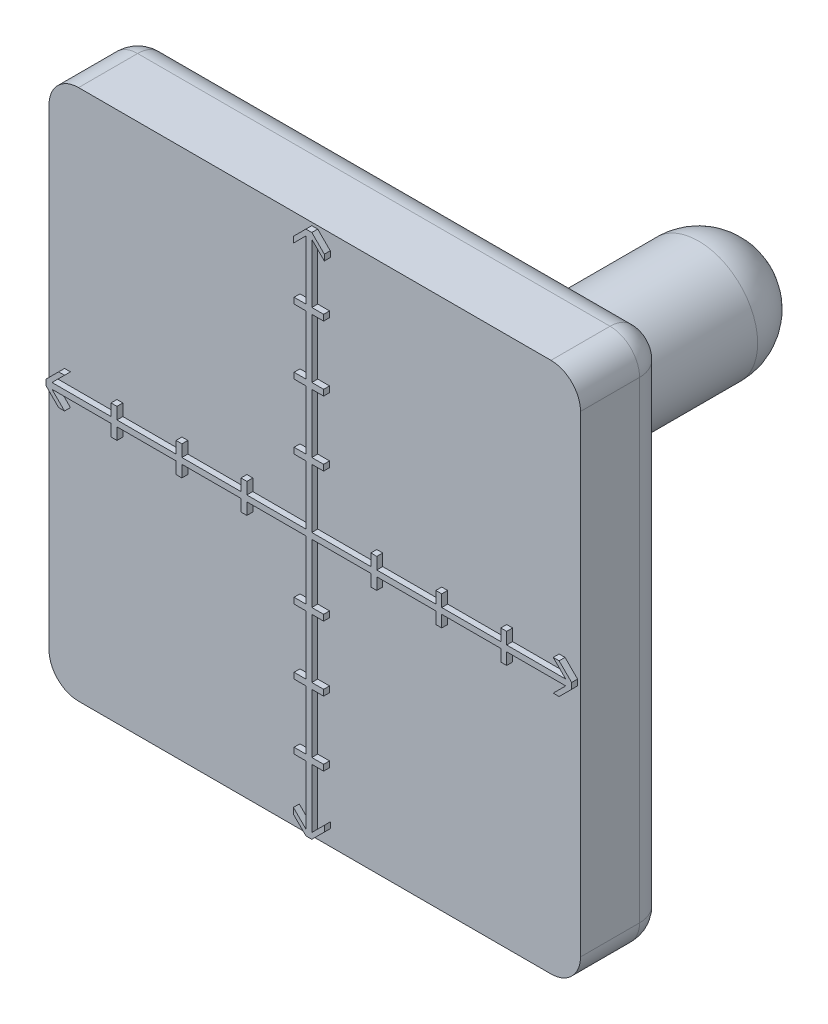
from build123d import *

# Parameters (mm, degrees)
CROQUIS1_W              = 90
CROQUIS1_H              = 90
SALIENTE_EXTRUIR2_DEPTH = 15
CROQUIS2_R              = 10
SALIENTE_EXTRUIR3_DEPTH = 60
SALIENTE_EXTRUIR4_DEPTH = 1
REDONDEO1_R             = 5
REDONDEO2_R             = 5
REDONDEO3_R             = 5
REDONDEO4_R             = 10


with BuildPart() as part:
    # Croquis1 → Saliente-Extruir2 (new body)
    with BuildSketch(Plane.XY):
        Rectangle(CROQUIS1_W, CROQUIS1_H)
    extrude(amount=SALIENTE_EXTRUIR2_DEPTH)

    # Croquis2 → Saliente-Extruir3 (add)
    with BuildSketch(Plane(origin=(0, 0, 0), x_dir=(-1, 0, 0), z_dir=(0, 0, -1))):
        Circle(CROQUIS2_R)
    extrude(amount=SALIENTE_EXTRUIR3_DEPTH)

    # Croquis3 → Saliente-Extruir4 (add)
    with BuildSketch(Plane.XY.offset(15)):
        Polygon((10.5, 0.5), (10.5, 2.5), (11.5, 2.5), (11.5, 0.5), (21.5, 0.5), (21.5, 2.5), (22.5, 2.5), (22.5, 0.5), (32.5, 0.5), (32.5, 2.5), (33.5, 2.5), (33.5, 0.5), (43.5, 0.5), (41.378679656, 2.621320344), (42.378679656, 2.621320344), (44.5, 0.5), (44.5, -0.5), (42.378679656, -2.621320344), (41.378679656, -2.621320344), (43.5, -0.5), (33.5, -0.5), (33.5, -2.5), (32.5, -2.5), (32.5, -0.5), (22.5, -0.5), (22.5, -2.5), (21.5, -2.5), (21.5, -0.5), (11.5, -0.5), (11.5, -2.5), (10.5, -2.5), (10.5, -0.5), (0.5, -0.5), (0.5, -10.5), (2.5, -10.5), (2.5, -11.5), (0.5, -11.5), (0.5, -21.5), (2.5, -21.5), (2.5, -22.5), (0.5, -22.5), (0.5, -32.5), (2.5, -32.5), (2.5, -33.5), (0.5, -33.5), (0.5, -43.5), (2.621320344, -41.378679656), (2.621320344, -42.378679656), (0.5, -44.5), (-0.5, -44.5), (-2.621320344, -42.378679656), (-2.621320344, -41.378679656), (-0.5, -43.5), (-0.5, -33.5), (-2.5, -33.5), (-2.5, -32.5), (-0.5, -32.5), (-0.5, -22.5), (-2.5, -22.5), (-2.5, -21.5), (-0.5, -21.5), (-0.5, -11.5), (-2.5, -11.5), (-2.5, -10.5), (-0.5, -10.5), (-0.5, -0.5), (-10.5, -0.5), (-10.5, -2.5), (-11.5, -2.5), (-11.5, -0.5), (-21.5, -0.5), (-21.5, -2.5), (-22.5, -2.5), (-22.5, -0.5), (-32.5, -0.5), (-32.5, -2.5), (-33.5, -2.5), (-33.5, -0.5), (-43.5, -0.5), (-41.378679656, -2.621320344), (-42.378679656, -2.621320344), (-44.5, -0.5), (-44.5, 0.5), (-42.378679656, 2.621320344), (-41.378679656, 2.621320344), (-43.5, 0.5), (-33.5, 0.5), (-33.5, 2.5), (-32.5, 2.5), (-32.5, 0.5), (-22.5, 0.5), (-22.5, 2.5), (-21.5, 2.5), (-21.5, 0.5), (-11.5, 0.5), (-11.5, 2.5), (-10.5, 2.5), (-10.5, 0.5), (-0.5, 0.5), (-0.5, 10.5), (-2.5, 10.5), (-2.5, 11.5), (-0.5, 11.5), (-0.5, 21.5), (-2.5, 21.5), (-2.5, 22.5), (-0.5, 22.5), (-0.5, 32.5), (-2.5, 32.5), (-2.5, 33.5), (-0.5, 33.5), (-0.5, 43.5), (-2.621320344, 41.378679656), (-2.621320344, 42.378679656), (-0.5, 44.5), (0.5, 44.5), (2.621320344, 42.378679656), (2.621320344, 41.378679656), (0.5, 43.5), (0.5, 33.5), (2.5, 33.5), (2.5, 32.5), (0.5, 32.5), (0.5, 22.5), (2.5, 22.5), (2.5, 21.5), (0.5, 21.5), (0.5, 11.5), (2.5, 11.5), (2.5, 10.5), (0.5, 10.5), (0.5, 0.5), align=None)
    extrude(amount=SALIENTE_EXTRUIR4_DEPTH)

    # Redondeo1
    redondeo1_edges = [part.edges().sort_by_distance(p)[0] for p in [
        (45, -45, 7.5),
        (-45, -45, 7.5),
        (-45, 45, 7.5),
        (45, 45, 7.5),
    ]]
    fillet(redondeo1_edges, radius=REDONDEO1_R)

    # Redondeo2
    redondeo2_edges = [part.edges().sort_by_distance(p)[0] for p in [
        (0, -45, 0),
        (45, 0, 0),
        (-45, 0, 0),
        (0, 45, 0),
        (43.535533906, 43.535533906, 0),
        (-43.535533906, 43.535533906, 0),
        (43.535533906, -43.535533906, 0),
        (-43.535533906, -43.535533906, 0),
    ]]
    fillet(redondeo2_edges, radius=REDONDEO2_R)

    # Redondeo3
    redondeo3_edges = [part.edges().sort_by_distance(p)[0] for p in [
        (10, 0, 0),
    ]]
    fillet(redondeo3_edges, radius=REDONDEO3_R)

    # Redondeo4
    redondeo4_edges = [part.edges().sort_by_distance(p)[0] for p in [
        (10, 0, -60),
    ]]
    fillet(redondeo4_edges, radius=REDONDEO4_R)


solid = part.part
